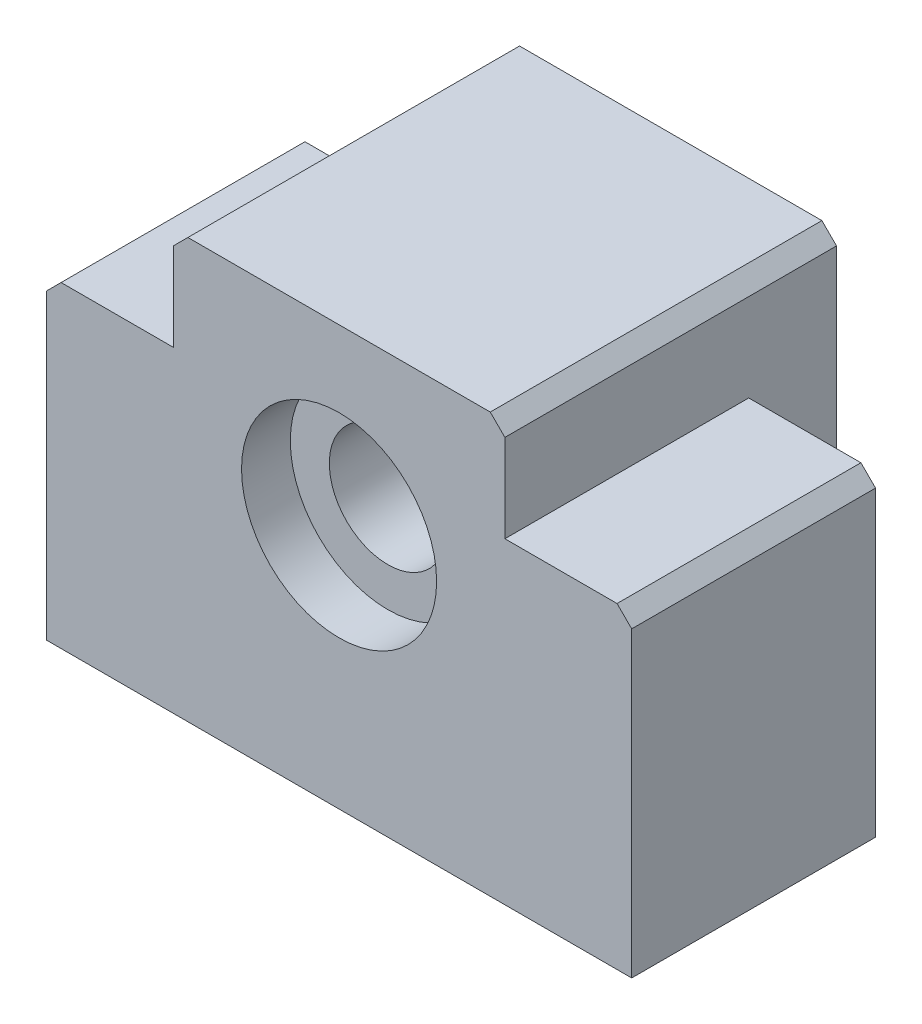
from build123d import *

# Parameters (mm, degrees)
CROQUIS1_W              = 60
CROQUIS1_H              = 32.5
SALIENTE_EXTRUIR1_DEPTH = 25
SALIENTE_EXTRUIR2_DEPTH = 34
CROQUIS3_R              = 6
CORTAR_EXTRUIR1_DEPTH   = 35
CHAFL_N1_SIZE           = 1.5
CHAFL_N2_SIZE           = 1.5
CHAFL_N3_SIZE           = 1.5
CROQUIS5_R              = 10
CORTAR_EXTRUIR2_DEPTH   = 15
CROQUIS6_R              = 10
CORTAR_EXTRUIR3_DEPTH   = 5


with BuildPart() as part:
    # Croquis1 → Saliente-Extruir1 (new body)
    with BuildSketch(Plane.XY):
        Rectangle(CROQUIS1_W, CROQUIS1_H)
    extrude(amount=SALIENTE_EXTRUIR1_DEPTH)

    # Croquis2 → Saliente-Extruir2 (add)
    with BuildSketch(Plane(origin=(0, 0, 25), x_dir=(-1, 0, 0), z_dir=(0, 0, -1))):
        Polygon((-17, 16.25), (-17, 26.75), (17, 26.75), (17, 16.25), (17, -9.25), (-17, -9.25), align=None)
    extrude(amount=SALIENTE_EXTRUIR2_DEPTH)

    # Croquis3 → Cortar-Extruir1 (cut, through all)
    with BuildSketch(Plane(origin=(0, 0, 25), x_dir=(-1, 0, 0), z_dir=(0, 0, -1))):
        with Locations((0, 8.95)):
            Circle(CROQUIS3_R)
    extrude(amount=CORTAR_EXTRUIR1_DEPTH, mode=Mode.SUBTRACT)

    # Chaflán1
    chafl_n1_edges = [part.edges().sort_by_distance(p)[0] for p in [
        (17, 26.75, 8),
    ]]
    chamfer(chafl_n1_edges, length=CHAFL_N1_SIZE)

    # Chaflán2
    chafl_n2_edges = [part.edges().sort_by_distance(p)[0] for p in [
        (-17, 26.75, 8),
    ]]
    chamfer(chafl_n2_edges, length=CHAFL_N2_SIZE)

    # Chaflán3
    chafl_n3_edges = [part.edges().sort_by_distance(p)[0] for p in [
        (-30, 16.25, 12.5),
        (30, 16.25, 12.5),
    ]]
    chamfer(chafl_n3_edges, length=CHAFL_N3_SIZE)

    # Croquis5 → Cortar-Extruir2 (cut)
    with BuildSketch(Plane.XY.offset(-9)):
        with Locations((0, 8.95)):
            Circle(CROQUIS5_R)
    extrude(amount=CORTAR_EXTRUIR2_DEPTH, mode=Mode.SUBTRACT)

    # Croquis6 → Cortar-Extruir3 (cut)
    with BuildSketch(Plane.XY.offset(25)):
        with Locations((0, 8.95)):
            Circle(CROQUIS6_R)
    extrude(amount=-CORTAR_EXTRUIR3_DEPTH, mode=Mode.SUBTRACT)


solid = part.part
